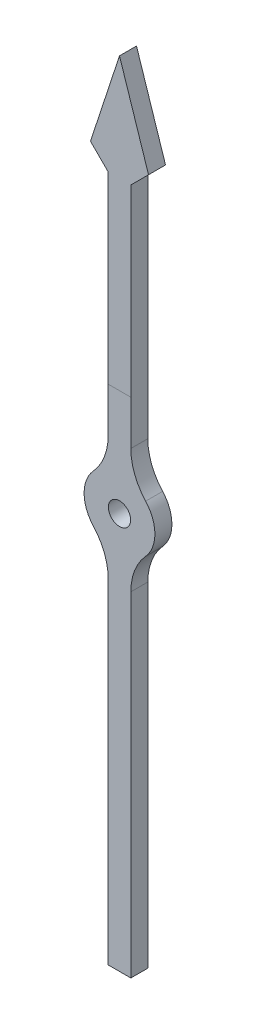
from build123d import *

# Parameters (mm, degrees)
SKETCH1_R           = 0.5
BOSS_EXTRUDE1_DEPTH = 0.762
FILLET1_R           = 2.54


with BuildPart() as part:
    # Sketch1 → Boss-Extrude1 (new body)
    with BuildSketch(Plane.XY):
        with BuildLine():
            Line((-0.508, 13.0175), (-1.30175, 13.81125))
            Line((-1.30175, 13.81125), (0, 17.78))
            Line((0, 17.78), (1.30175, 13.81125))
            Line((1.30175, 13.81125), (0.508, 13.0175))
            Line((0.508, 13.0175), (0.508, 1.504025349))
            ThreePointArc((0.508, 1.504025349), (1.5875, 0), (0.508, -1.504025349))
            Line((0.508, -1.504025349), (0.508, -17.78))
            Line((0.508, -17.78), (-0.508, -17.78))
            Line((-0.508, -17.78), (-0.508, -1.504025349))
            ThreePointArc((-0.508, -1.504025349), (-1.5875, 0), (-0.508, 1.504025349))
            Line((-0.508, 1.504025349), (-0.508, 13.0175))
        make_face()
        Circle(SKETCH1_R, mode=Mode.SUBTRACT)
    extrude(amount=BOSS_EXTRUDE1_DEPTH)

    # Fillet1
    fillet1_edges = [part.edges().sort_by_distance(p)[0] for p in [
        (0.508, -1.504025349, 0.381),
        (-0.508, -1.504025349, 0.381),
        (-0.508, 1.504025349, 0.381),
        (0.508, 1.504025349, 0.381),
    ]]
    fillet(fillet1_edges, radius=FILLET1_R)


solid = part.part
